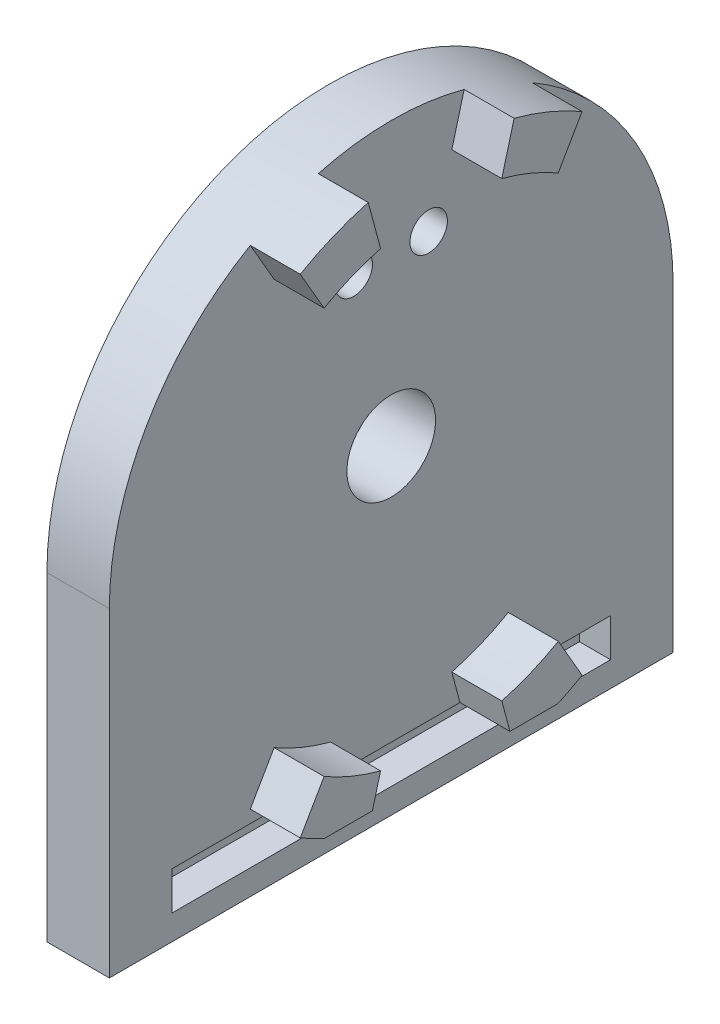
from build123d import *

# Parameters (mm, degrees)
SKETCH1_R               = 22.567960526
BOSS_EXTRUDE1_DEPTH     = 5
SKETCH2_W               = 45.135921052
SKETCH2_H               = 25.616013259
BOSS_EXTRUDE2_DEPTH     = 5
SKETCH3_R               = 1.5
SKETCH3_R_2             = 3.55
CUT_EXTRUDE1_DEPTH      = 1
CUT_EXTRUDE1_DEPTH_BACK = 6
SKETCH4_W               = 35.135921052
SKETCH4_H               = 3.066013259
CUT_EXTRUDE2_DEPTH      = 2.5
BOSS_EXTRUDE3_DEPTH     = 4


with BuildPart() as part:
    # Sketch1 → Boss-Extrude1 (new body)
    with BuildSketch(Plane(origin=(0, 0, 0), x_dir=(0, 0, -1), z_dir=(1, 0, 0))):
        Circle(SKETCH1_R)
    extrude(amount=BOSS_EXTRUDE1_DEPTH)

    # Sketch2 → Boss-Extrude2 (add)
    with BuildSketch(Plane(origin=(5, 0, 0), x_dir=(0, 0, -1), z_dir=(1, 0, 0))):
        with Locations((0, -12.80800663)):
            Rectangle(SKETCH2_W, SKETCH2_H)
    extrude(amount=-BOSS_EXTRUDE2_DEPTH)

    # Sketch3 → Cut-Extrude1 (cut, two sides)
    with BuildSketch(Plane(origin=(5, 0, 0), x_dir=(0, 0, -1), z_dir=(1, 0, 0))) as cut_extrude1_sk:
        with Locations((-3, 13.371154887)):
            Circle(SKETCH3_R)
        with Locations((3, 13.371154887)):
            Circle(SKETCH3_R)
        Circle(SKETCH3_R_2)
    extrude(amount=CUT_EXTRUDE1_DEPTH, mode=Mode.SUBTRACT)
    extrude(cut_extrude1_sk.sketch, amount=-CUT_EXTRUDE1_DEPTH_BACK, mode=Mode.SUBTRACT)

    # Sketch4 → Cut-Extrude2 (cut)
    with BuildSketch(Plane(origin=(5, 0, 0), x_dir=(0, 0, -1), z_dir=(1, 0, 0))):
        with Locations((0, -22.08300663)):
            Rectangle(SKETCH4_W, SKETCH4_H)
    extrude(amount=-CUT_EXTRUDE2_DEPTH, mode=Mode.SUBTRACT)

    # Sketch5 → Boss-Extrude3 (add)
    with BuildSketch(Plane(origin=(5, 0, 0), x_dir=(0, 0, -1), z_dir=(1, 0, 0))):
        with BuildLine():
            Line((-11.283980263, 19.544427127), (-9.375, 16.237976321))
            ThreePointArc((-9.375, 16.237976321), (-7.175314357, 17.322741235), (-4.852857096, 18.111109243))
            Line((-4.852857096, 18.111109243), (-5.841017993, 21.798975919))
            ThreePointArc((-5.841017993, 21.798975919), (-8.636384596, 20.850076821), (-11.283980263, 19.544427127))
        make_face()
        with BuildLine():
            Line((5.841017993, 21.798975919), (4.852857096, 18.111109243))
            ThreePointArc((4.852857096, 18.111109243), (7.175314357, 17.322741235), (9.375, 16.237976321))
            Line((9.375, 16.237976321), (11.283980263, 19.544427127))
            ThreePointArc((11.283980263, 19.544427127), (8.636384596, 20.850076821), (5.841017993, 21.798975919))
        make_face()
        with BuildLine():
            Line((-5.506355904, -20.55), (-4.852857096, -18.111109243))
            ThreePointArc((-4.852857096, -18.111109243), (-7.175314357, -17.322741235), (-9.375, -16.237976321))
            Line((-9.375, -16.237976321), (-11.283980263, -19.544427127))
            ThreePointArc((-11.283980263, -19.544427127), (-10.318214034, -20.071056312), (-9.327933443, -20.55))
            Line((-9.327933443, -20.55), (-5.506355904, -20.55))
        make_face()
        with BuildLine():
            Line((11.283980263, -19.544427127), (9.375, -16.237976321))
            ThreePointArc((9.375, -16.237976321), (7.175314357, -17.322741235), (4.852857096, -18.111109243))
            Line((4.852857096, -18.111109243), (5.506355904, -20.55))
            Line((5.506355904, -20.55), (9.327933443, -20.55))
            ThreePointArc((9.327933443, -20.55), (10.318214034, -20.071056312), (11.283980263, -19.544427127))
        make_face()
    extrude(amount=BOSS_EXTRUDE3_DEPTH)


solid = part.part
